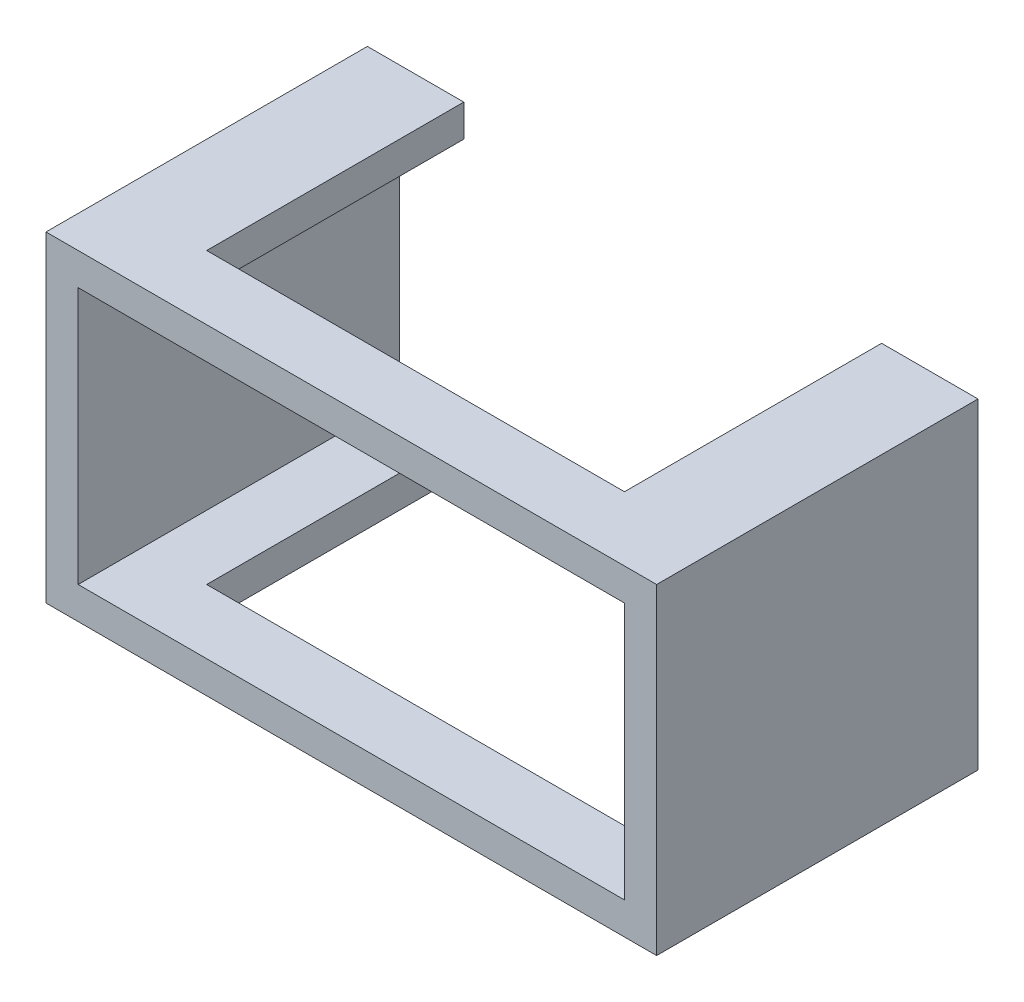
from build123d import *

# Parameters (mm, degrees)
SKETCH1_W           = 19
SKETCH1_H           = 10
BOSS_EXTRUDE1_DEPTH = 10
SKETCH2_W           = 17
SKETCH2_H           = 8
CUT_EXTRUDE1_DEPTH  = 12
SKETCH3_W           = 13
SKETCH3_H           = 10.51996768
CUT_EXTRUDE3_DEPTH  = 8


with BuildPart() as part:
    # Sketch1 → Boss-Extrude1 (new body)
    with BuildSketch(Plane.XY):
        with Locations((-0.130136986, 2.22260274)):
            Rectangle(SKETCH1_W, SKETCH1_H)
    extrude(amount=BOSS_EXTRUDE1_DEPTH)

    # Sketch2 → Cut-Extrude1 (cut)
    with BuildSketch(Plane.XY.offset(10)):
        with Locations((-0.130136986, 2.22260274)):
            Rectangle(SKETCH2_W, SKETCH2_H)
    extrude(amount=-CUT_EXTRUDE1_DEPTH, mode=Mode.SUBTRACT)

    # Sketch3 → Cut-Extrude3 (cut)
    with BuildSketch(Plane.XY):
        with Locations((-0.130136986, 2.34516547)):
            Rectangle(SKETCH3_W, SKETCH3_H)
    extrude(amount=CUT_EXTRUDE3_DEPTH, mode=Mode.SUBTRACT)


solid = part.part
